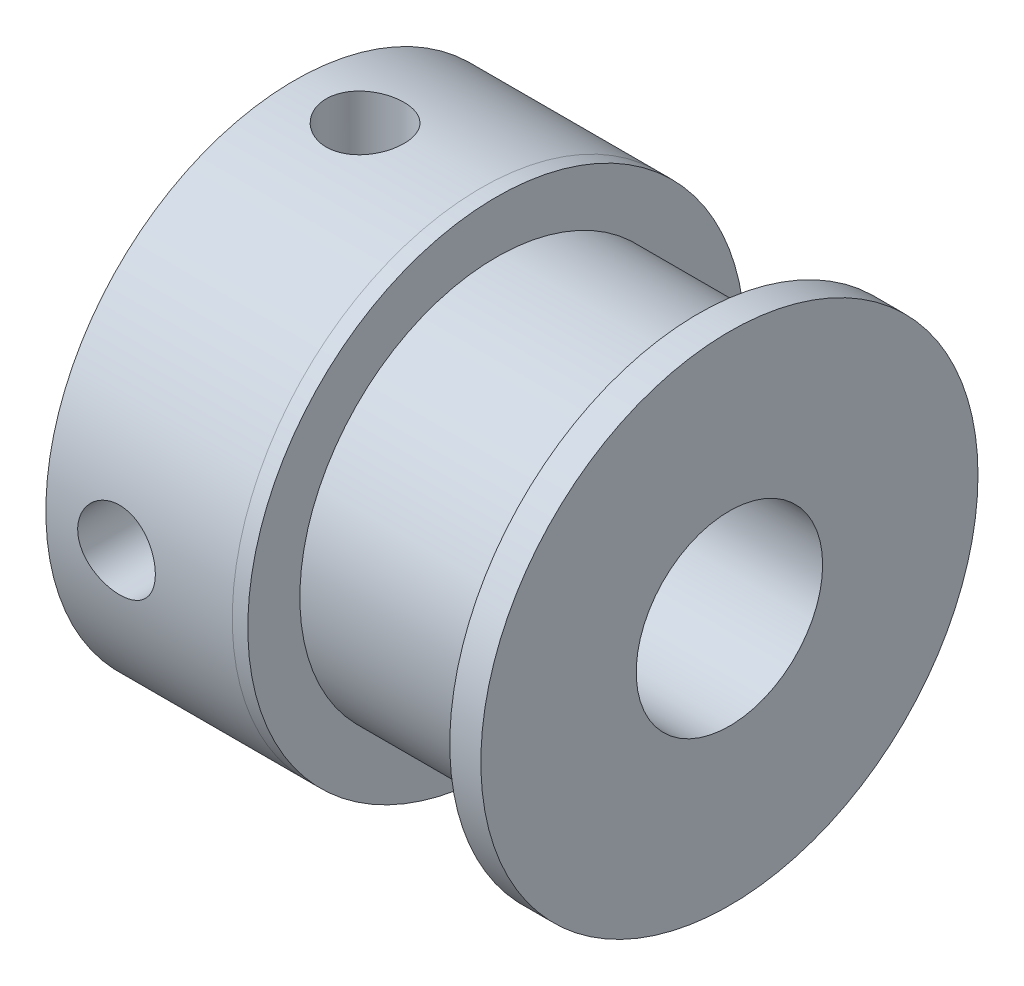
from build123d import *

# Parameters (mm, degrees)
SKETCH2_W = 1.25
SKETCH2_H = 8
SKETCH4_W = 1.25
SKETCH4_H = 8


with BuildPart() as part:
    # Sketch1 → Revolve1 (revolve)
    with BuildSketch(Plane.XY):
        Polygon((1.451473536, 3), (1.451473536, 7.999829628), (7.451473536, 8), (7.951473536, 8), (7.951473536, 6.325), (14.451473536, 6.325), (14.451473536, 8), (15.451473536, 8), (15.451473536, 3), align=None)
    revolve(axis=Axis((0, 0, 0), (-1, 0, 0)))

    # Sketch2 → M3x0.5 Tapped Hole1 (revolve, cut)
    with BuildSketch(Plane(origin=(3.725736768, 0, 0), x_dir=(0, 0, -1), z_dir=(1, 0, 0))):
        with Locations((0.625, 4)):
            Rectangle(SKETCH2_W, SKETCH2_H)
    revolve(axis=Axis((3.725736768, -6.35, 0), (0, 1, 0)), mode=Mode.SUBTRACT)

    # Sketch4 → M3x0.5 Tapped Hole2 (revolve, cut)
    with BuildSketch(Plane.YZ.offset(3.725736768)):
        with Locations((0.625, 4)):
            Rectangle(SKETCH4_W, SKETCH4_H)
    revolve(axis=Axis((3.725736768, 0, -6.35), (0, 0, 1)), mode=Mode.SUBTRACT)


solid = part.part
